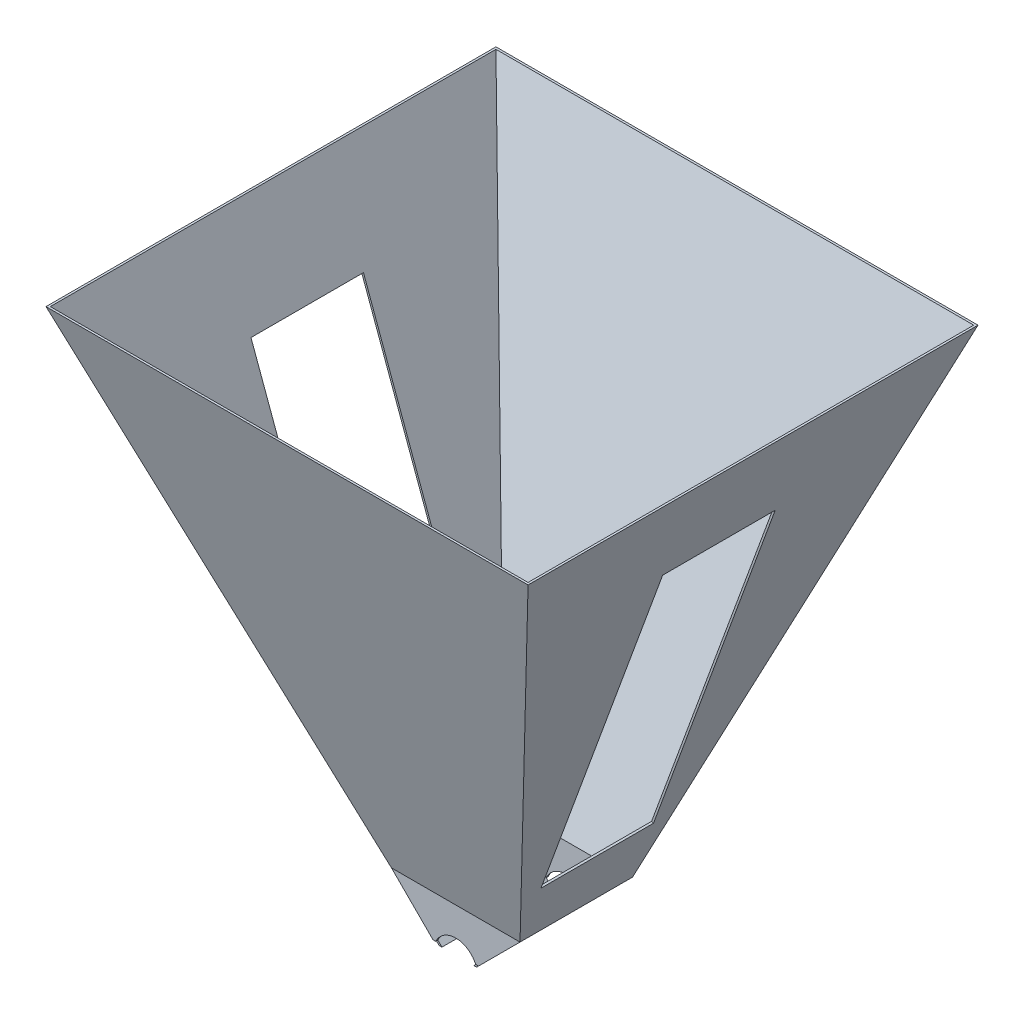
from build123d import *

# Parameters (mm, degrees)
BOSS_EXTRUDE1_DEPTH     = 1.5875
BOSS_EXTRUDE2_DEPTH     = 85.725
BOSS_EXTRUDE3_DEPTH     = 1.5875
CUT_EXTRUDE3_DEPTH      = 1
CUT_EXTRUDE3_DEPTH_BACK = 89.9
CUT_EXTRUDE4_DEPTH      = 1.651
CUT_EXTRUDE5_DEPTH      = 1.651
SKETCH13_W              = 36.910686819
SKETCH13_H              = 2.125129036
CUT_EXTRUDE6_DEPTH      = 2.651
CUT_EXTRUDE6_DEPTH_BACK = 88.249
SKETCH5_W               = 101.6
SKETCH5_H               = 88.9
SKETCH4_W               = 381
SKETCH4_H               = 355.6
SHELL1_T                = -1.5875
SKETCH6_W               = 88.937676789
SKETCH6_H               = 279.4
CUT_EXTRUDE1_DEPTH      = 2.54
SKETCH8_W               = 88.9
SKETCH8_H               = 279.4
CUT_EXTRUDE2_DEPTH      = 2.54


with BuildPart() as part:
    # Sketch1 → Boss-Extrude1 (new body)
    with BuildSketch(Plane.XY):
        Polygon((-12.7, 0), (12.7, 0), (50.8, 38.1), (-50.8, 38.1), align=None)
    extrude(amount=-BOSS_EXTRUDE1_DEPTH)

    # Sketch2 → Boss-Extrude2 (add)
    with BuildSketch(Plane(origin=(0, 0, -1.5875), x_dir=(-1, 0, 0), z_dir=(0, 0, -1))):
        Polygon((12.7, 0), (50.8, 38.1), (48.55493597, 38.1), (10.45493597, 0), align=None)
        Polygon((-48.55493597, 38.1), (-10.45493597, 0), (-12.7, 0), (-50.8, 38.1), align=None)
    extrude(amount=BOSS_EXTRUDE2_DEPTH)

    # Sketch3 → Boss-Extrude3 (add)
    with BuildSketch(Plane(origin=(0, 0, -87.3125), x_dir=(-1, 0, 0), z_dir=(0, 0, -1))):
        Polygon((-50.8, 38.1), (-12.7, 0), (12.7, 0), (50.8, 38.1), align=None)
    extrude(amount=BOSS_EXTRUDE3_DEPTH)

    # Sketch9 → Cut-Extrude3 (cut, two sides)
    with BuildSketch(Plane.XY) as cut_extrude3_sk:
        with BuildLine():
            Line((-15.755065006, 5.300129036), (-10.45493597, 0))
            Line((-10.45493597, 0), (10.45493597, 0))
            Line((10.45493597, 0), (15.755065006, 5.300129036))
            ThreePointArc((15.755065006, 5.300129036), (0, 15.494), (-15.755065006, 5.300129036))
        make_face()
    extrude(amount=CUT_EXTRUDE3_DEPTH, mode=Mode.SUBTRACT)
    extrude(cut_extrude3_sk.sketch, amount=-CUT_EXTRUDE3_DEPTH_BACK, mode=Mode.SUBTRACT)

    # Sketch10 → Cut-Extrude4 (cut)
    with BuildSketch(Plane.XY):
        Polygon((-10.45493597, 0), (-12.7, 0), (-18.000129036, 5.300129036), (-15.755065006, 5.300129036), align=None)
        Polygon((10.45493597, 0), (12.7, 0), (18.000129036, 5.300129036), (15.755065006, 5.300129036), align=None)
    extrude(amount=-CUT_EXTRUDE4_DEPTH, mode=Mode.SUBTRACT)

    # Sketch12 → Cut-Extrude5 (cut)
    with BuildSketch(Plane(origin=(0, 0, -88.9), x_dir=(-1, 0, 0), z_dir=(0, 0, -1))):
        Polygon((10.45493597, 0), (12.7, 0), (18.000129036, 5.300129036), (15.755065006, 5.300129036), align=None)
        Polygon((-18.000129036, 5.300129036), (-12.7, 0), (-10.45493597, 0), (-15.755065006, 5.300129036), align=None)
    extrude(amount=-CUT_EXTRUDE5_DEPTH, mode=Mode.SUBTRACT)

    # Sketch13 → Cut-Extrude6 (cut, two sides)
    with BuildSketch(Plane.XY.offset(-1.651)) as cut_extrude6_sk:
        with Locations((0.072881206, 1.062564518)):
            Rectangle(SKETCH13_W, SKETCH13_H)
    extrude(amount=CUT_EXTRUDE6_DEPTH, mode=Mode.SUBTRACT)
    extrude(cut_extrude6_sk.sketch, amount=-CUT_EXTRUDE6_DEPTH_BACK, mode=Mode.SUBTRACT)


with BuildPart() as body_2:
    # Sketch5 → Loft1 section 0
    with BuildSketch(Plane(origin=(0, 38.1, 0), x_dir=(1, 0, 0), z_dir=(0, 1, 0))):
        with Locations((0, 44.45)):
            Rectangle(SKETCH5_W, SKETCH5_H)
    # Sketch4 → Loft1 section 1
    with BuildSketch(Plane(origin=(0, 419.1, 0), x_dir=(1, 0, 0), z_dir=(0, 1, 0))):
        with Locations((0, 44.45)):
            Rectangle(SKETCH4_W, SKETCH4_H)
    loft()

    # Shell1
    shell1_openings = [body_2.faces().sort_by_distance(p)[0] for p in [
        (-95.25, 419.1, 44.45),
        (0, 38.1, -66.675),
    ]]
    offset(amount=SHELL1_T, openings=shell1_openings, kind=Kind.INTERSECTION)

    # Sketch6 → Cut-Extrude1 (cut)
    with BuildSketch(Plane(origin=(32.465230167, -11.903917728, 0), x_dir=(0, 0, -1), z_dir=(0.938876316, -0.344254649, 0))):
        with Locations((44.431161606, 241.106310622)):
            Rectangle(SKETCH6_W, SKETCH6_H)
    extrude(amount=-CUT_EXTRUDE1_DEPTH, mode=Mode.SUBTRACT)

    # Sketch8 → Cut-Extrude2 (cut)
    with BuildSketch(Plane(origin=(-32.465230167, -11.903917728, 0), x_dir=(0, 0, 1), z_dir=(-0.938876316, -0.344254649, 0))):
        with Locations((-44.45, 240.451979822)):
            Rectangle(SKETCH8_W, SKETCH8_H)
    extrude(amount=-CUT_EXTRUDE2_DEPTH, mode=Mode.SUBTRACT)


solid = Compound([part.part, body_2.part])
